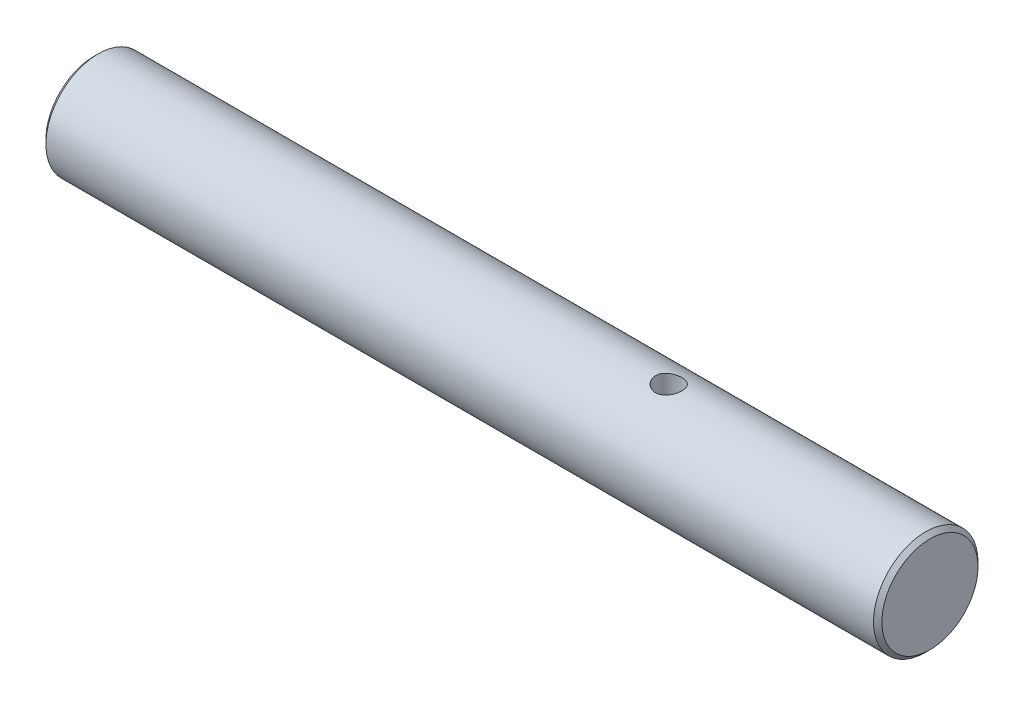
from build123d import *

# Parameters (mm, degrees)
SKETCH1_R               = 3.175
BOSS_EXTRUDE1_DEPTH     = 50.8
CHAMFER1_SIZE           = 0.254
SKETCH2_R               = 0.8001
CUT_EXTRUDE1_DEPTH      = 4.175
CUT_EXTRUDE1_DEPTH_BACK = 4.175


with BuildPart() as part:
    # Sketch1 → Boss-Extrude1 (new body)
    with BuildSketch(Plane(origin=(0, 0, 0), x_dir=(0, 0, -1), z_dir=(1, 0, 0))):
        Circle(SKETCH1_R)
    extrude(amount=-BOSS_EXTRUDE1_DEPTH)

    # Chamfer1
    chamfer1_edges = [part.edges().sort_by_distance(p)[0] for p in [
        (0, 0, 3.175),
        (-50.8, 0, 3.175),
    ]]
    chamfer(chamfer1_edges, length=CHAMFER1_SIZE)

    # Sketch2 → Cut-Extrude1 (cut, two sides)
    with BuildSketch(Plane(origin=(0, 0, 0), x_dir=(1, 0, 0), z_dir=(0, 1, 0))) as cut_extrude1_sk:
        with Locations((-15.875, 0)):
            Circle(SKETCH2_R)
    extrude(amount=CUT_EXTRUDE1_DEPTH, mode=Mode.SUBTRACT)
    extrude(cut_extrude1_sk.sketch, amount=-CUT_EXTRUDE1_DEPTH_BACK, mode=Mode.SUBTRACT)


solid = part.part
